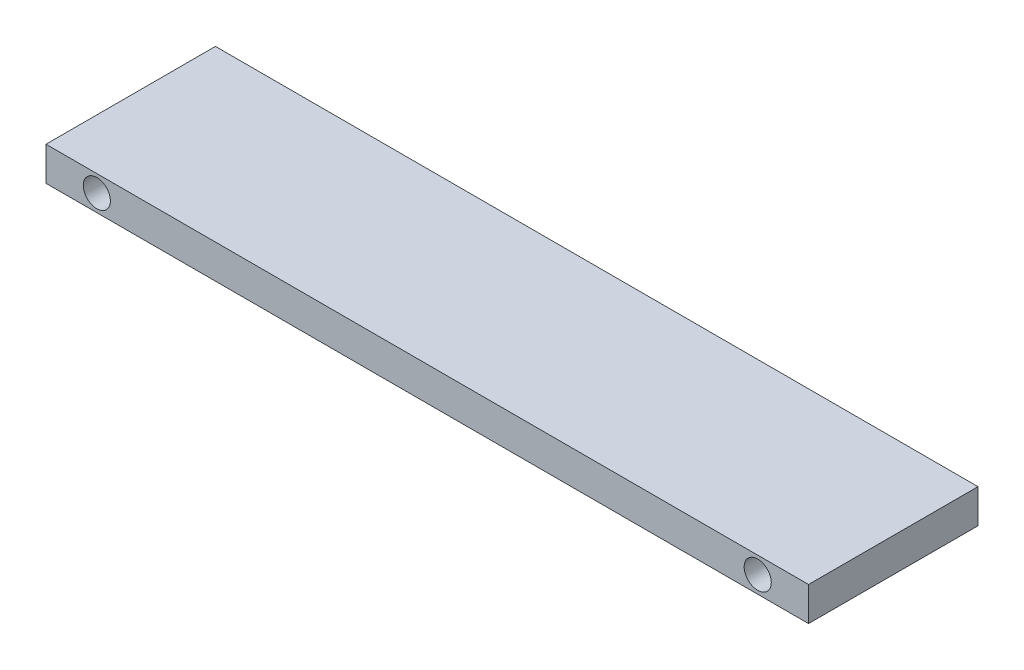
from build123d import *

# Parameters (mm, degrees)
SKETCH1_W           = 450
SKETCH1_H           = 100
BOSS_EXTRUDE1_DEPTH = 20
SKETCH2_R           = 8
CUT_EXTRUDE1_DEPTH  = 101


with BuildPart() as part:
    # Sketch1 → Boss-Extrude1 (new body)
    with BuildSketch(Plane(origin=(0, 0, 0), x_dir=(1, 0, 0), z_dir=(0, 1, 0))):
        Rectangle(SKETCH1_W, SKETCH1_H)
    extrude(amount=BOSS_EXTRUDE1_DEPTH)

    # Sketch2 → Cut-Extrude1 (cut, through all)
    with BuildSketch(Plane.XY.offset(50)):
        with Locations((195, 10)):
            Circle(SKETCH2_R)
        with Locations((-195, 10)):
            Circle(SKETCH2_R)
    extrude(amount=-CUT_EXTRUDE1_DEPTH, mode=Mode.SUBTRACT)


solid = part.part
